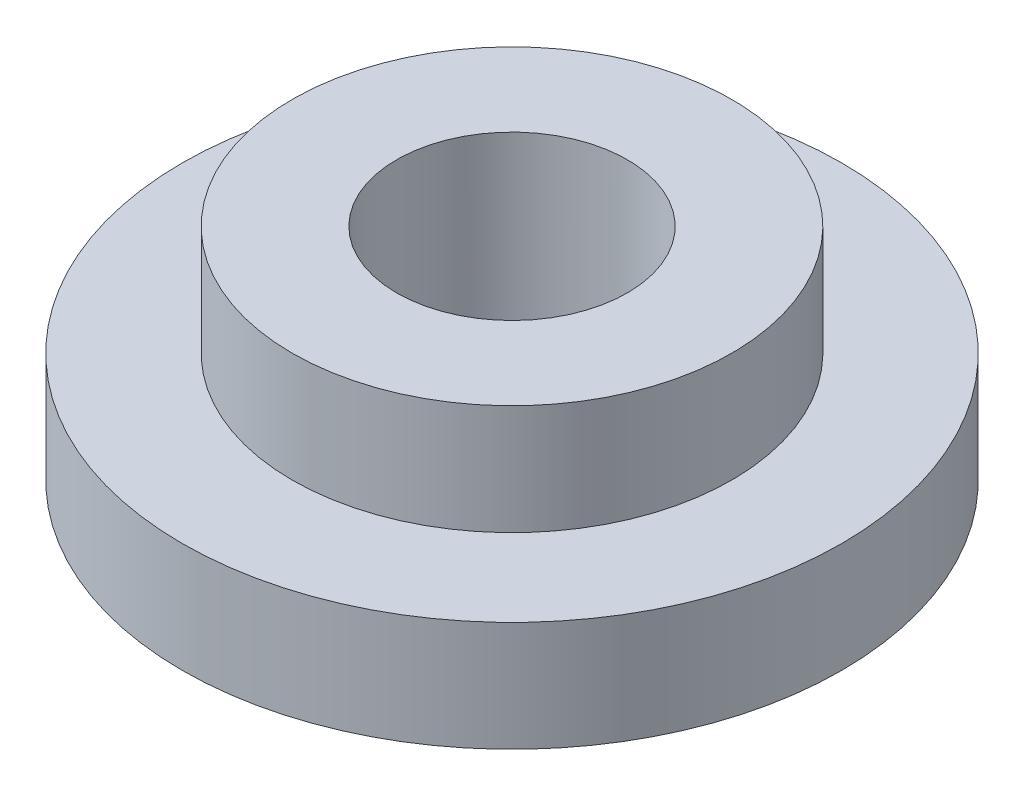
from build123d import *

# Parameters (mm, degrees)
SKETCH1_R               = 6
BOSS_EXTRUDE1_DEPTH     = 2
SKETCH2_R               = 4
BOSS_EXTRUDE2_DEPTH     = 2
SKETCH3_R               = 2.1
CUT_EXTRUDE1_DEPTH      = 1
CUT_EXTRUDE1_DEPTH_BACK = 5
SKETCH4_R               = 3.5
SKETCH4_R_2             = 2.1
BOSS_EXTRUDE3_DEPTH     = 1


with BuildPart() as part:
    # Sketch1 → Boss-Extrude1 (new body)
    with BuildSketch(Plane(origin=(0, 0, 0), x_dir=(1, 0, 0), z_dir=(0, 1, 0))):
        Circle(SKETCH1_R)
    extrude(amount=BOSS_EXTRUDE1_DEPTH)

    # Sketch2 → Boss-Extrude2 (add)
    with BuildSketch(Plane(origin=(0, 2, 0), x_dir=(1, 0, 0), z_dir=(0, 1, 0))):
        Circle(SKETCH2_R)
    extrude(amount=BOSS_EXTRUDE2_DEPTH)

    # Sketch3 → Cut-Extrude1 (cut, two sides)
    with BuildSketch(Plane(origin=(0, 4, 0), x_dir=(1, 0, 0), z_dir=(0, 1, 0))) as cut_extrude1_sk:
        Circle(SKETCH3_R)
    extrude(amount=CUT_EXTRUDE1_DEPTH, mode=Mode.SUBTRACT)
    extrude(cut_extrude1_sk.sketch, amount=-CUT_EXTRUDE1_DEPTH_BACK, mode=Mode.SUBTRACT)

    # Sketch4 → Boss-Extrude3 (add)
    with BuildSketch(Plane.XZ):
        Circle(SKETCH4_R)
        Circle(SKETCH4_R_2, mode=Mode.SUBTRACT)
    extrude(amount=BOSS_EXTRUDE3_DEPTH)


solid = part.part
